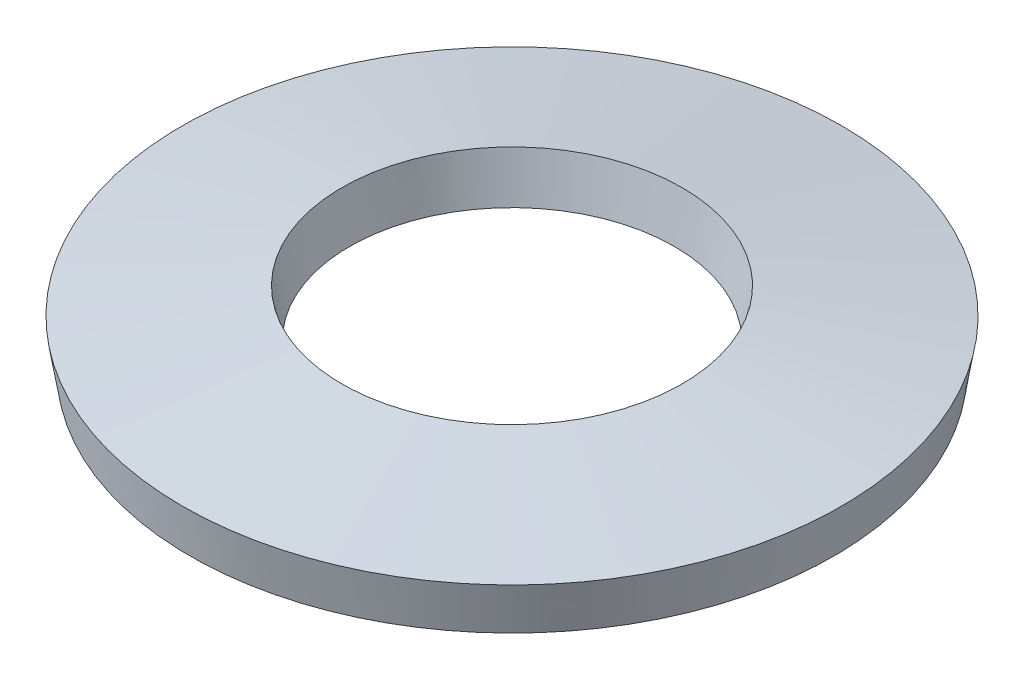
from build123d import *


with BuildPart() as part:
    # Sketch1 → Revolve1 (revolve)
    with BuildSketch(Plane.XY):
        Polygon((10.107692353, 0), (5.1, 0.819700367), (5.342307647, 2.3), (10.35, 1.480299633), align=None)
    revolve(axis=Axis((0, 0, 0), (0, 1, 0)))


solid = part.part
